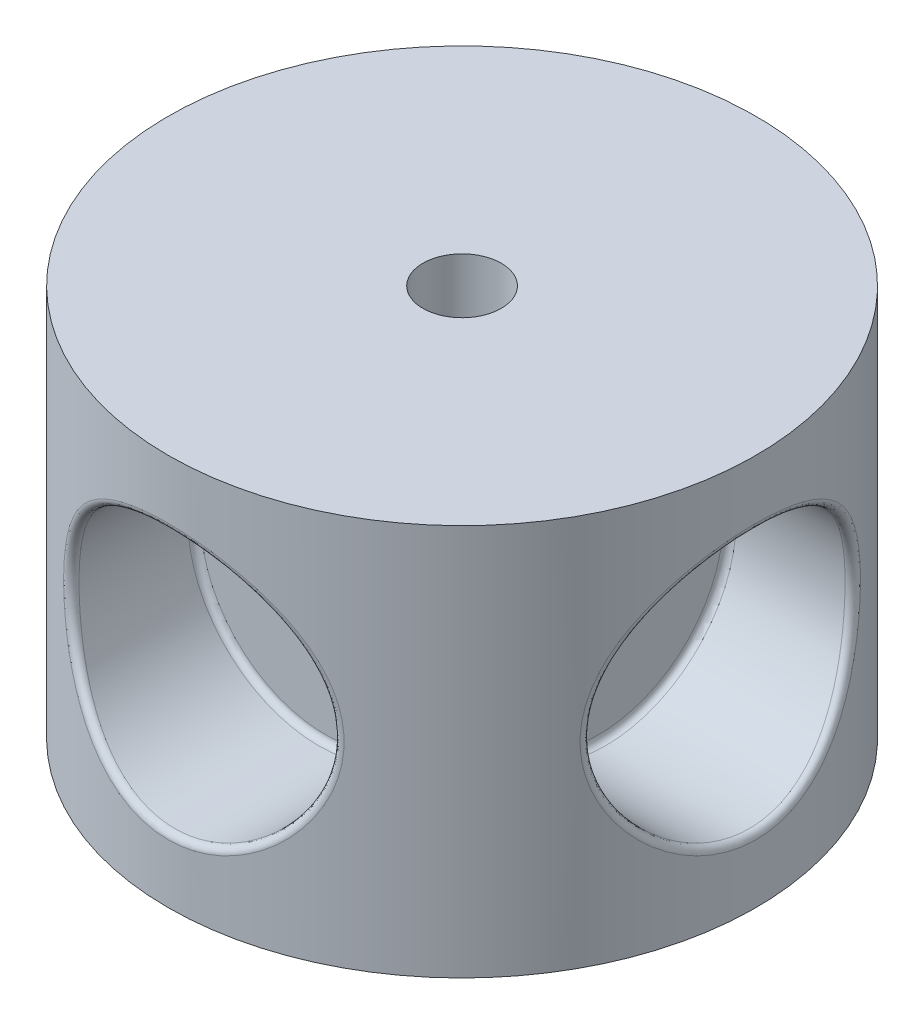
from build123d import *

# Parameters (mm, degrees)
CROQUIS1_R              = 22.5
SALIENTE_EXTRUIR1_DEPTH = 30
CROQUIS3_R              = 10
CORTAR_EXTRUIR1_DEPTH   = 12
REDONDEO1_R             = 0.5
MATRIZC4_COUNT          = 4
REDONDEO1_OF_MATRIZC4_R = 0.5
CROQUIS4_R              = 3
CORTAR_EXTRUIR2_DEPTH   = 30
CROQUIS5_W              = 15
CROQUIS5_H              = 2
CORTAR_EXTRUIR3_DEPTH   = 5


with BuildPart() as part:
    # Croquis1 → Saliente-Extruir1 (new body)
    with BuildSketch(Plane(origin=(0, 0, 0), x_dir=(1, 0, 0), z_dir=(0, 1, 0))):
        with Locations(Location((0, 0, 0), (0, 0, 270))):  # turned: the seam where the file's is
            Circle(CROQUIS1_R)
    extrude(amount=SALIENTE_EXTRUIR1_DEPTH)

    # Croquis3 → Cortar-Extruir1 (cut)
    with BuildSketch(Plane.ZY.offset(22.5)):
        with Locations((0, 15)):
            Circle(CROQUIS3_R)
    cortar_extruir1 = extrude(amount=-CORTAR_EXTRUIR1_DEPTH, mode=Mode.SUBTRACT)

    # Redondeo1
    redondeo1_edges = [part.edges().sort_by_distance(p)[0] for p in [
        (-20.155644371, 15, -10),
        (-10.5, 15, -10),
    ]]
    fillet(redondeo1_edges, radius=REDONDEO1_R)

    # MatrizC4: Cortar-Extruir1 ×4 about axis
    matrizc4_axis = Axis((0, 30, 0), (0, -1, 0))
    for i in range(1, MATRIZC4_COUNT):
        add(cortar_extruir1.rotate(matrizc4_axis, i * 360 / MATRIZC4_COUNT), mode=Mode.SUBTRACT)

    # Redondeo1 of MatrizC4
    redondeo1_of_matrizc4_edges = [part.edges().sort_by_distance(p)[0] for p in [
        (10, 15, -20.155644371),
        (10, 15, -10.5),
        (20.155644371, 15, 10),
        (10.5, 15, 10),
        (-10, 15, 20.155644371),
        (-10, 15, 10.5),
    ]]
    fillet(redondeo1_of_matrizc4_edges, radius=REDONDEO1_OF_MATRIZC4_R)

    # Croquis4 → Cortar-Extruir2 (cut)
    with BuildSketch(Plane.XZ):
        with Locations(Location((0, 0, 0), (0, 0, 270))):  # turned: the seam where the file's is
            Circle(CROQUIS4_R)
    extrude(amount=-CORTAR_EXTRUIR2_DEPTH, mode=Mode.SUBTRACT)

    # Croquis5 → Cortar-Extruir3 (cut)
    with BuildSketch(Plane.XZ):
        Rectangle(CROQUIS5_W, CROQUIS5_H)
    extrude(amount=-CORTAR_EXTRUIR3_DEPTH, mode=Mode.SUBTRACT)


solid = part.part
